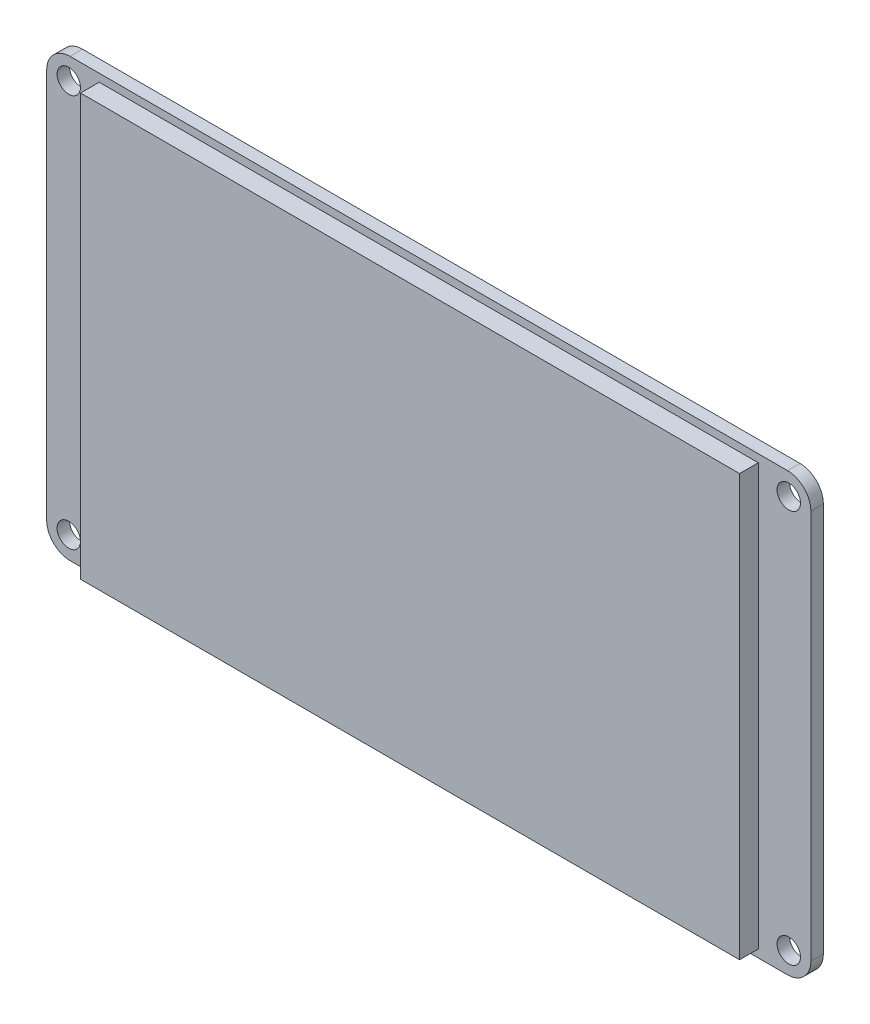
from build123d import *

# Parameters (mm, degrees)
ESBO_O1_R                = 1.5
RESSALTO_EXTRUS_O1_DEPTH = 1.6
ESBO_O1_3_W              = 84.52
ESBO_O1_3_H              = 54
RESSALTO_EXTRUS_O2_DEPTH = 4


with BuildPart() as part:
    # Esboço1 → Ressalto-extrusão1 (new body)
    with BuildSketch(Plane.XY):
        with BuildLine():
            Line((46, 28), (-46, 28))
            ThreePointArc((-46, 28), (-48.121320344, 27.121320344), (-49, 25))
            Line((-49, 25), (-49, -25))
            ThreePointArc((-49, -25), (-48.121320344, -27.121320344), (-46, -28))
            Line((-46, -28), (46, -28))
            ThreePointArc((46, -28), (48.121320344, -27.121320344), (49, -25))
            Line((49, -25), (49, 25))
            ThreePointArc((49, 25), (48.121320344, 27.121320344), (46, 28))
        make_face()
        with Locations((-46.165, -25.21)):
            Circle(ESBO_O1_R, mode=Mode.SUBTRACT)
        with Locations((46.165, -25.21)):
            Circle(ESBO_O1_R, mode=Mode.SUBTRACT)
        with Locations((-46.165, 25.21)):
            Circle(ESBO_O1_R, mode=Mode.SUBTRACT)
        with Locations((46.165, 25.21)):
            Circle(ESBO_O1_R, mode=Mode.SUBTRACT)
    extrude(amount=RESSALTO_EXTRUS_O1_DEPTH)

    # Esboço1<3> → Ressalto-extrusão2 (add)
    with BuildSketch(Plane.XY):
        Rectangle(ESBO_O1_3_W, ESBO_O1_3_H)
    extrude(amount=RESSALTO_EXTRUS_O2_DEPTH)


solid = part.part
